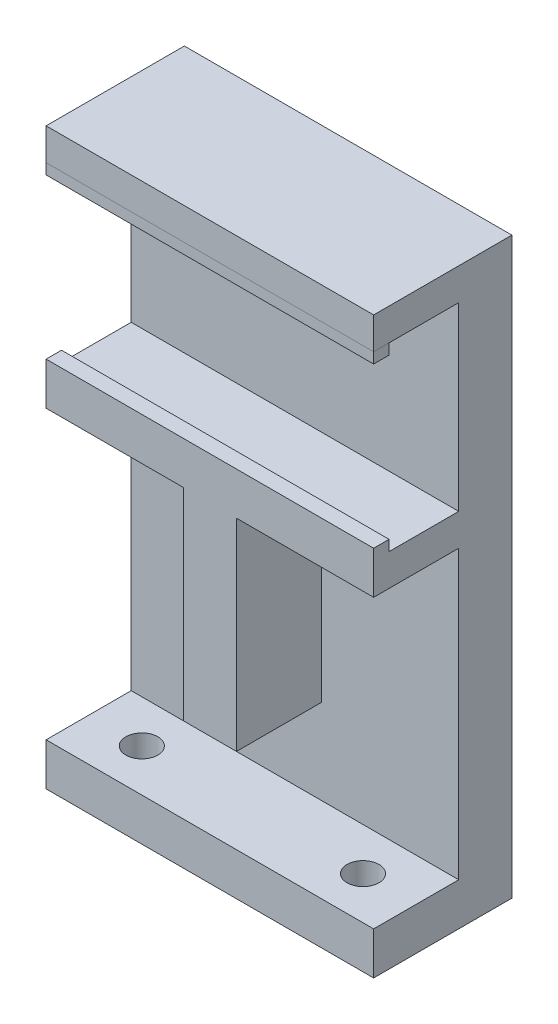
from build123d import *

# Parameters (mm, degrees)
SKETCH_1_W          = 30.8
SKETCH_1_H          = 39
EXTRUDE_1_DEPTH     = 5
SKETCH_2_W          = 30.8
SKETCH_2_H          = 3
EXTRUDE_2_DEPTH     = 8
SKETCH_3_W          = 5
SKETCH_3_H          = 19
EXTRUDE_3_DEPTH     = 8
EXTRUDE_4_DEPTH     = 30.8
SKETCH_5_R          = 1.5
CUT_EXTRUDE_1_DEPTH = 4
SKETCH_6_W          = 1.45
SKETCH_6_H          = 1
EXTRUDE_5_DEPTH     = 30.8
SKETCH_7_W          = 30.8
SKETCH_7_H          = 3
EXTRUDE_6_DEPTH     = 5


with BuildPart() as part:
    # 草图1 → 凸台-拉伸1 (new body)
    with BuildSketch(Plane.XY):
        with Locations((15.4, 19.5)):
            Rectangle(SKETCH_1_W, SKETCH_1_H)
    extrude(amount=EXTRUDE_1_DEPTH)

    # 草图2 → 凸台-拉伸2 (add)
    with BuildSketch(Plane.XY.offset(5)):
        with Locations((15.4, 40.5)):
            Rectangle(SKETCH_2_W, SKETCH_2_H)
        with Locations((15.4, 20.5)):
            Rectangle(SKETCH_2_W, SKETCH_2_H)
    extrude(amount=EXTRUDE_2_DEPTH)


with BuildPart() as extrude_2_piece_1:
    # of the separate pieces the step leaves, piece 1, a body of its own (extrude_2_pieces)
    add(part.part.solids().sort_by_distance((0, 0, 0))[0])

    # 草图3 → 凸台-拉伸3 (add)
    with BuildSketch(Plane.XY.offset(5)):
        with Locations((15.4, 9.5)):
            Rectangle(SKETCH_3_W, SKETCH_3_H)
    extrude(amount=EXTRUDE_3_DEPTH)

    # 草图4 → 凸台-拉伸4 (add)
    with BuildSketch(Plane(origin=(30.8, 0, 0), x_dir=(0, 0, -1), z_dir=(1, 0, 0))):
        Polygon((-5, 0), (-5, -8), (-13, -8), (-13, -12), (0, -12), (0, 0), align=None)
    extrude(amount=-EXTRUDE_4_DEPTH)

    # 草图5 → 切除-拉伸1 (cut)
    with BuildSketch(Plane(origin=(0, -8, 0), x_dir=(1, 0, 0), z_dir=(0, 1, 0))):
        with Locations(Location((5, -9, 0), (0, 0, 270))):
            Circle(SKETCH_5_R)
        with Locations(Location((25.8, -9, 0), (0, 0, 270))):
            Circle(SKETCH_5_R)
    extrude(amount=-CUT_EXTRUDE_1_DEPTH, mode=Mode.SUBTRACT)

    # 草图6 → 凸台-拉伸5 (add, through all)
    with BuildSketch(Plane(origin=(30.8, 0, 0), x_dir=(0, 0, -1), z_dir=(1, 0, 0))):
        with Locations((-12.275, 38.5)):
            Rectangle(SKETCH_6_W, SKETCH_6_H)
        with Locations((-12.275, 22.5)):
            Rectangle(SKETCH_6_W, SKETCH_6_H)
    extrude(amount=-EXTRUDE_5_DEPTH)


with BuildPart() as extrude_2_piece_2:
    # of the separate pieces the step leaves, piece 2, a body of its own (extrude_2_pieces)
    add(part.part.solids().sort_by_distance((30.8, 39, 13))[0])



with BuildPart() as extrude_5_piece_1:
    # of the separate pieces the step leaves, piece 1, a body of its own (extrude_5_pieces)
    add(extrude_2_piece_1.part.solids().sort_by_distance((17.9, 0, 5))[0])


with BuildPart() as extrude_5_piece_2:
    # of the separate pieces the step leaves, piece 2, a body of its own (extrude_5_pieces)
    add(extrude_2_piece_1.part.solids().sort_by_distance((30.8, 39, 13))[0])


with BuildPart() as extrude_2_piece_2_1:
    add(extrude_2_piece_2.part)

    add(extrude_5_piece_1.part)  # 凸台-拉伸6 merges 凸台-拉伸5 piece 1
    # 草图7 → 凸台-拉伸6 (add)
    with BuildSketch(Plane(origin=(0, 0, 5), x_dir=(-1, 0, 0), z_dir=(0, 0, -1))):
        with Locations((-15.4, 40.5)):
            Rectangle(SKETCH_7_W, SKETCH_7_H)
    extrude(amount=EXTRUDE_6_DEPTH)


solid = Compound([extrude_5_piece_2.part, extrude_2_piece_2_1.part])
